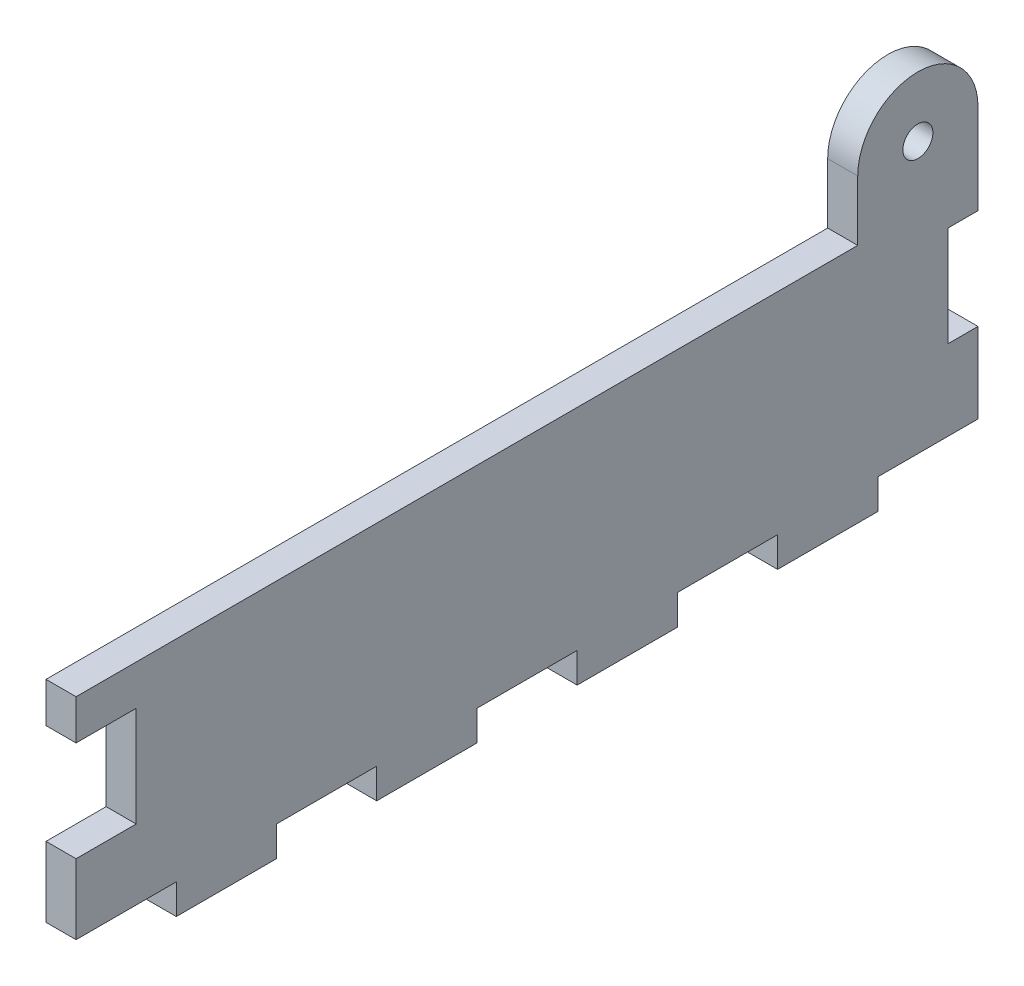
from build123d import *

# Parameters (mm, degrees)
SKETCH1_R           = 1.5
BOSS_EXTRUDE1_DEPTH = 3


with BuildPart() as part:
    # Sketch1 → Boss-Extrude1 (new body)
    with BuildSketch(Plane(origin=(0, 0, 0), x_dir=(0, 0, -1), z_dir=(1, 0, 0))):
        with BuildLine():
            Line((81.277391257, 21), (81.277391257, 18))
            Line((81.277391257, 18), (78.277391257, 18))
            Line((78.277391257, 18), (78.277391257, 8))
            Line((78.277391257, 8), (81.277391257, 8))
            Line((81.277391257, 8), (81.277391257, 0))
            Line((81.277391257, 0), (71.277391257, 0))
            Line((71.277391257, 0), (71.277391257, -3))
            Line((71.277391257, -3), (61.277391257, -3))
            Line((61.277391257, -3), (61.277391257, 0))
            Line((61.277391257, 0), (51.277391257, 0))
            Line((51.277391257, 0), (51.277391257, -3))
            Line((51.277391257, -3), (41.277391257, -3))
            Line((41.277391257, -3), (41.277391257, 0))
            Line((41.277391257, 0), (31.277391257, 0))
            Line((31.277391257, 0), (31.277391257, -3))
            Line((31.277391257, -3), (21.277391257, -3))
            Line((21.277391257, -3), (21.277391257, 0))
            Line((21.277391257, 0), (11.277391257, 0))
            Line((11.277391257, 0), (11.277391257, -3))
            Line((11.277391257, -3), (1.277391257, -3))
            Line((1.277391257, -3), (1.277391257, 0))
            Line((1.277391257, 0), (-8.722608743, 0))
            Line((-8.722608743, 0), (-8.722608743, 7))
            Line((-8.722608743, 7), (-2.722608743, 7))
            Line((-2.722608743, 7), (-2.722608743, 17))
            Line((-2.722608743, 17), (-8.722608743, 17))
            Line((-8.722608743, 17), (-8.722608743, 21))
            Line((-8.722608743, 21), (69.277391257, 21))
            Line((69.277391257, 21), (69.277391257, 27))
            ThreePointArc((69.277391257, 27), (75.277391257, 33), (81.277391257, 27))
            Line((81.277391257, 27), (81.277391257, 21))
        make_face()
        with Locations((75.277391257, 27)):
            Circle(SKETCH1_R, mode=Mode.SUBTRACT)
    extrude(amount=BOSS_EXTRUDE1_DEPTH)


solid = part.part
